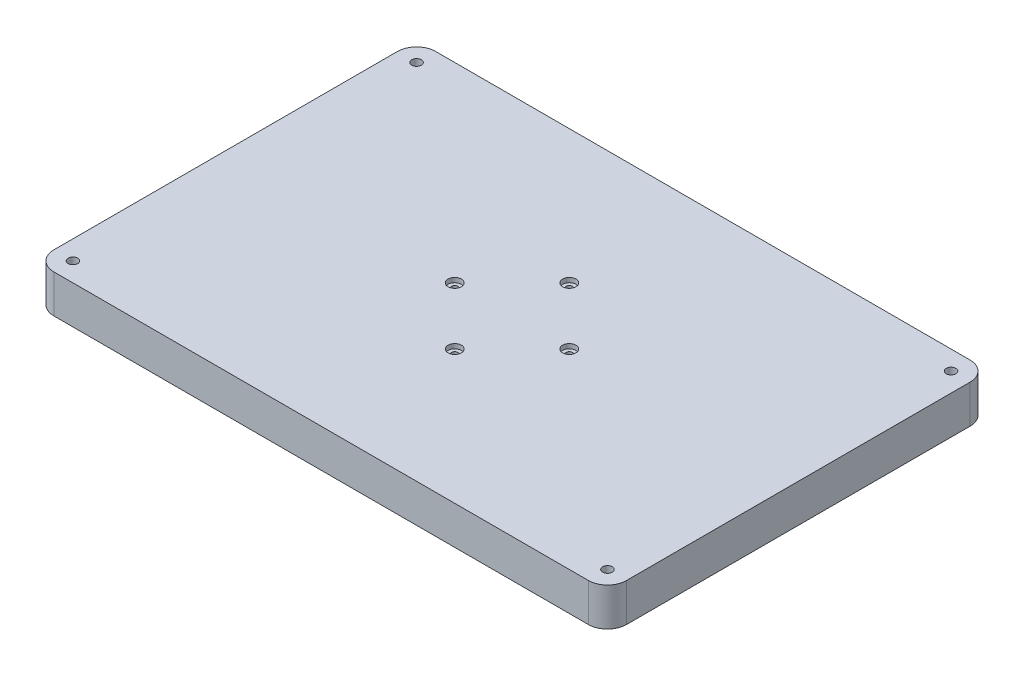
from build123d import *

# Parameters (mm, degrees)
SKETCH1_W                                        = 300
SKETCH1_H                                        = 200
BOSS_EXTRUDE1_DEPTH                              = 20
FILLET1_R                                        = 10
CBORE_FOR_M3_PAN_HEAD_MACHINE_SCREW1_D           = 3.4
CBORE_FOR_M3_PAN_HEAD_MACHINE_SCREW1_CBORE_D     = 7
CBORE_FOR_M3_PAN_HEAD_MACHINE_SCREW1_CBORE_DEPTH = 2.4
F_5_0_5_DIAMETER_HOLE1_D                         = 5
F_2_0_2_DIAMETER_HOLE1_D                         = 2
F_2_0_2_DIAMETER_HOLE1_DEPTH                     = 10
F_2_0_2_DIAMETER_HOLE1_TIP                       = 0.600860619


with BuildPart() as part:
    # Sketch1 → Boss-Extrude1 (new body)
    with BuildSketch(Plane(origin=(0, 0, 0), x_dir=(1, 0, 0), z_dir=(0, 1, 0))):
        Rectangle(SKETCH1_W, SKETCH1_H)
    extrude(amount=BOSS_EXTRUDE1_DEPTH)

    # Fillet1
    fillet1_edges = [part.edges().sort_by_distance(p)[0] for p in [
        (-150, 10, -100),
        (150, 10, -100),
        (150, 10, 100),
        (-150, 10, 100),
    ]]
    fillet(fillet1_edges, radius=FILLET1_R)

    # CBORE for M3 Pan Head Machine Screw1 (through all)
    with Locations(Plane(origin=(0, 20, 0), x_dir=(1, 0, 0), z_dir=(0, 1, 0))):
        with Locations((-30, 0), (0, -30), (30, 0), (0, 30)):
            CounterBoreHole(CBORE_FOR_M3_PAN_HEAD_MACHINE_SCREW1_D / 2, CBORE_FOR_M3_PAN_HEAD_MACHINE_SCREW1_CBORE_D / 2, CBORE_FOR_M3_PAN_HEAD_MACHINE_SCREW1_CBORE_DEPTH)

    # Ø5.0 (5) Diameter Hole1 (through all)
    with Locations(Plane(origin=(0, 20, 0), x_dir=(1, 0, 0), z_dir=(0, 1, 0))):
        with Locations((-140, 90), (140, 90), (140, -90), (-140, -90)):
            Hole(F_5_0_5_DIAMETER_HOLE1_D / 2)

    # Ø2.0 (2) Diameter Hole1
    with Locations(Plane(origin=(0, 0, 0), x_dir=(-1, 0, 0), z_dir=(0, -1, 0))):
        with Locations((129.008456627, -60.281417871), (123.889747092, -7.883242209), (95.98974887, -7.893204139), (80.707888413, -58.698663894)):
            Hole(F_2_0_2_DIAMETER_HOLE1_D / 2, depth=F_2_0_2_DIAMETER_HOLE1_DEPTH)
            with Locations((0, 0, -(F_2_0_2_DIAMETER_HOLE1_DEPTH + F_2_0_2_DIAMETER_HOLE1_TIP / 2))):  # 118° drill point
                Cone(0, F_2_0_2_DIAMETER_HOLE1_D / 2, F_2_0_2_DIAMETER_HOLE1_TIP, mode=Mode.SUBTRACT)


solid = part.part
